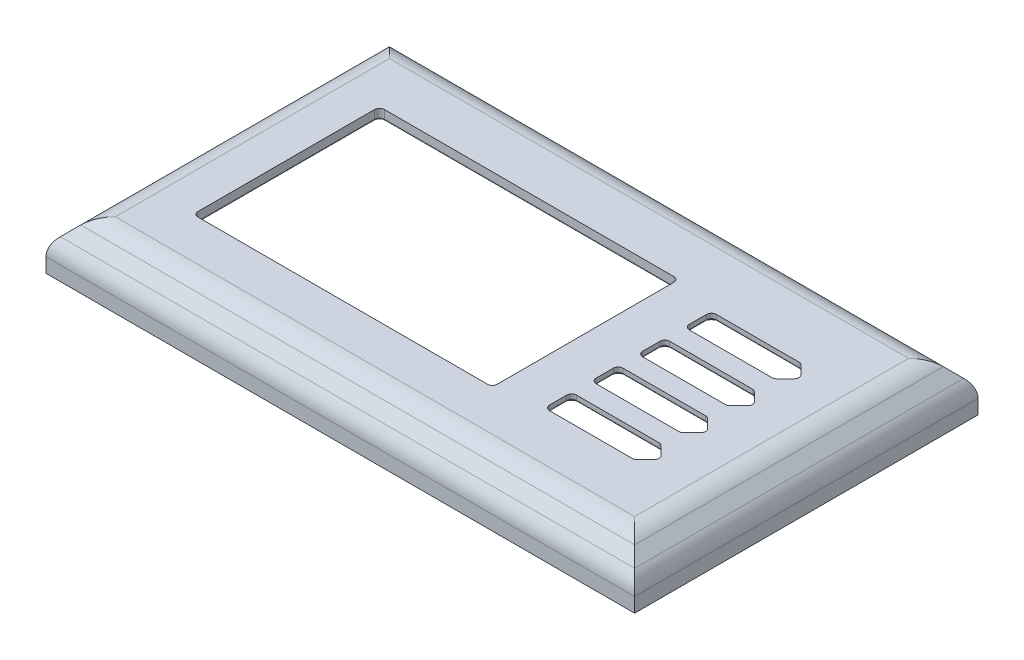
from build123d import *

# Parameters (mm, degrees)
SKETCH1_W           = 120
SKETCH1_H           = 70
BOSS_EXTRUDE1_DEPTH = 10
CHAMFER1_SIZE       = 5
SHELL1_T            = -2
SKETCH2_W           = 61
SKETCH2_H           = 38
CUT_EXTRUDE1_DEPTH  = 11
FILLET8_R           = 1
FILLET10_R          = 5
CUT_EXTRUDE3_DEPTH  = 0.8
FILLET12_R          = 0.3
FILLET13_R          = 0.3
SKETCH4_W           = 116.2
SKETCH4_H           = 66.2
CUT_EXTRUDE6_DEPTH  = 2


with BuildPart() as part:
    # Sketch1 → Boss-Extrude1 (new body)
    with BuildSketch(Plane(origin=(0, 0, 0), x_dir=(1, 0, 0), z_dir=(0, 1, 0))):
        with Locations((60, 35)):
            Rectangle(SKETCH1_W, SKETCH1_H)
    extrude(amount=BOSS_EXTRUDE1_DEPTH)

    # Chamfer1
    chamfer1_edges = [part.edges().sort_by_distance(p)[0] for p in [
        (120, 10, -35),
        (60, 10, -70),
        (0, 10, -35),
        (60, 10, 0),
    ]]
    chamfer(chamfer1_edges, length=CHAMFER1_SIZE)

    # Shell1
    shell1_openings = [part.faces().sort_by_distance(p)[0] for p in [
        (60, 0, -35),
    ]]
    offset(amount=SHELL1_T, openings=shell1_openings, kind=Kind.INTERSECTION)

    # Sketch2 → Cut-Extrude1 (cut, through all)
    with BuildSketch(Plane(origin=(0, 10, 0), x_dir=(1, 0, 0), z_dir=(0, 1, 0))):
        with Locations((45.067653297, 34.427439967)):
            Rectangle(SKETCH2_W, SKETCH2_H)
        Polygon((84.567653297, 41.583069286), (84.567653297, 36.083069286), (102.817653297, 36.083069286), (105.567653297, 38.833069286), (102.817653297, 41.583069286), align=None)
        Polygon((105.567653297, 48.333069286), (102.817653297, 51.083069286), (84.567653297, 51.083069286), (84.567653297, 45.583069286), (102.817653297, 45.583069286), align=None)
        Polygon((84.567653297, 32.083069286), (84.567653297, 26.583069286), (102.817653297, 26.583069286), (105.567653297, 29.333069286), (102.817653297, 32.083069286), align=None)
        Polygon((84.567653297, 22.583069286), (84.567653297, 17.083069286), (102.817653297, 17.083069286), (105.567653297, 19.833069286), (102.817653297, 22.583069286), align=None)
    extrude(amount=-CUT_EXTRUDE1_DEPTH, mode=Mode.SUBTRACT)

    # Fillet8
    fillet8_edges = [part.edges().sort_by_distance(p)[0] for p in [
        (84.567653297, 9, -26.583069286),
        (84.567653297, 9, -32.083069286),
        (102.817653297, 9, -32.083069286),
        (105.567653297, 9, -29.333069286),
        (102.817653297, 9, -26.583069286),
        (84.567653297, 9, -17.083069286),
        (84.567653297, 9, -22.583069286),
        (102.817653297, 9, -22.583069286),
        (105.567653297, 9, -19.833069286),
        (102.817653297, 9, -17.083069286),
        (14.567653297, 9, -15.427439967),
        (14.567653297, 9, -53.427439967),
        (75.567653297, 9, -53.427439967),
        (75.567653297, 9, -15.427439967),
        (84.567653297, 9, -45.583069286),
        (84.567653297, 9, -51.083069286),
        (102.817653297, 9, -51.083069286),
        (105.567653297, 9, -48.333069286),
        (102.817653297, 9, -45.583069286),
        (84.567653297, 9, -36.083069286),
        (84.567653297, 9, -41.583069286),
        (102.817653297, 9, -41.583069286),
        (105.567653297, 9, -38.833069286),
        (102.817653297, 9, -36.083069286),
    ]]
    fillet(fillet8_edges, radius=FILLET8_R)

    # Fillet10
    fillet10_edges = [part.edges().sort_by_distance(p)[0] for p in [
        (60, 10, -5),
        (5, 10, -35),
        (60, 10, -65),
        (115, 10, -35),
        (120, 5, -35),
        (60, 5, -70),
        (0, 5, -35),
        (60, 5, 0),
        (2, 4.171572875, -35),
        (60, 4.171572875, -2),
        (118, 4.171572875, -35),
        (60, 4.171572875, -68),
        (60, 8, -5.828427125),
        (114.171572875, 8, -35),
        (60, 8, -64.171572875),
        (5.828427125, 8, -35),
    ]]
    fillet(fillet10_edges, radius=FILLET10_R)

    # Sketch3 → Cut-Extrude3 (cut)
    with BuildSketch(Plane.XZ.offset(-8)):
        with BuildLine():
            Line((83.567653297, -31.083069286), (83.567653297, -27.583069286))
            ThreePointArc((83.567653297, -27.583069286), (84.153439735, -26.168855723), (85.567653297, -25.583069286))
            Line((85.567653297, -25.583069286), (102.403439735, -25.583069286))
            ThreePointArc((102.403439735, -25.583069286), (103.168806599, -25.735310221), (103.817653297, -26.168855723))
            Line((103.817653297, -26.168855723), (105.567653297, -27.918855723))
            ThreePointArc((105.567653297, -27.918855723), (106.153439735, -29.333069286), (105.567653297, -30.747282848))
            Line((105.567653297, -30.747282848), (103.817653297, -32.497282848))
            ThreePointArc((103.817653297, -32.497282848), (103.168806599, -32.930828351), (102.403439735, -33.083069286))
            Line((102.403439735, -33.083069286), (85.567653297, -33.083069286))
            ThreePointArc((85.567653297, -33.083069286), (84.153439735, -32.497282848), (83.567653297, -31.083069286))
        make_face()
        with BuildLine():
            Line((103.817653297, -16.668855723), (105.567653297, -18.418855723))
            ThreePointArc((105.567653297, -18.418855723), (106.153439735, -19.833069286), (105.567653297, -21.247282848))
            Line((105.567653297, -21.247282848), (103.817653297, -22.997282848))
            ThreePointArc((103.817653297, -22.997282848), (103.168806599, -23.430828351), (102.403439735, -23.583069286))
            Line((102.403439735, -23.583069286), (85.567653297, -23.583069286))
            ThreePointArc((85.567653297, -23.583069286), (84.153439735, -22.997282848), (83.567653297, -21.583069286))
            Line((83.567653297, -21.583069286), (83.567653297, -18.083069286))
            ThreePointArc((83.567653297, -18.083069286), (84.153439735, -16.668855723), (85.567653297, -16.083069286))
            Line((85.567653297, -16.083069286), (102.403439735, -16.083069286))
            ThreePointArc((102.403439735, -16.083069286), (103.168806599, -16.235310221), (103.817653297, -16.668855723))
        make_face()
        with BuildLine():
            Line((83.567653297, -40.583069286), (83.567653297, -37.083069286))
            ThreePointArc((83.567653297, -37.083069286), (84.153439735, -35.668855723), (85.567653297, -35.083069286))
            Line((85.567653297, -35.083069286), (102.403439735, -35.083069286))
            ThreePointArc((102.403439735, -35.083069286), (103.168806599, -35.235310221), (103.817653297, -35.668855723))
            Line((103.817653297, -35.668855723), (105.567653297, -37.418855723))
            ThreePointArc((105.567653297, -37.418855723), (106.153439735, -38.833069286), (105.567653297, -40.247282848))
            Line((105.567653297, -40.247282848), (103.817653297, -41.997282848))
            ThreePointArc((103.817653297, -41.997282848), (103.168806599, -42.430828351), (102.403439735, -42.583069286))
            Line((102.403439735, -42.583069286), (85.567653297, -42.583069286))
            ThreePointArc((85.567653297, -42.583069286), (84.153439735, -41.997282848), (83.567653297, -40.583069286))
        make_face()
        with BuildLine():
            Line((83.567653297, -50.083069286), (83.567653297, -46.583069286))
            ThreePointArc((83.567653297, -46.583069286), (84.153439735, -45.168855723), (85.567653297, -44.583069286))
            Line((85.567653297, -44.583069286), (102.403439735, -44.583069286))
            ThreePointArc((102.403439735, -44.583069286), (103.168806599, -44.735310221), (103.817653297, -45.168855723))
            Line((103.817653297, -45.168855723), (105.567653297, -46.918855723))
            ThreePointArc((105.567653297, -46.918855723), (106.153439735, -48.333069286), (105.567653297, -49.747282848))
            Line((105.567653297, -49.747282848), (103.817653297, -51.497282848))
            ThreePointArc((103.817653297, -51.497282848), (103.168806599, -51.930828351), (102.403439735, -52.083069286))
            Line((102.403439735, -52.083069286), (85.567653297, -52.083069286))
            ThreePointArc((85.567653297, -52.083069286), (84.153439735, -51.497282848), (83.567653297, -50.083069286))
        make_face()
    extrude(amount=-CUT_EXTRUDE3_DEPTH, mode=Mode.SUBTRACT)

    # Fillet12
    fillet12_edges = [part.edges().sort_by_distance(p)[0] for p in [
        (105.153439735, 8.8, -29.333069286),
        (93.985546516, 8.8, -32.083069286),
        (103.985546516, 8.8, -30.915176067),
        (103.985546516, 8.8, -27.750962504),
        (103.168806599, 8, -32.930828351),
        (104.692653297, 8, -31.622282848),
        (106.153439735, 8, -29.333069286),
        (104.692653297, 8, -27.043855723),
        (103.168806599, 8, -25.735310221),
        (93.985546516, 8, -25.583069286),
        (84.153439735, 8, -26.168855723),
        (83.567653297, 8, -29.333069286),
        (84.153439735, 8, -32.497282848),
        (93.985546516, 8, -33.083069286),
        (84.860546516, 8.8, -31.790176067),
        (84.567653297, 8.8, -29.333069286),
        (84.860546516, 8.8, -26.875962504),
        (93.985546516, 8.8, -26.583069286),
        (102.786123167, 8.8, -26.659189753),
        (102.786123167, 8.8, -32.006948818),
        (105.153439735, 8.8, -19.833069286),
        (93.985546516, 8.8, -22.583069286),
        (103.985546516, 8.8, -21.415176067),
        (103.985546516, 8.8, -18.250962504),
        (103.168806599, 8, -23.430828351),
        (104.692653297, 8, -22.122282848),
        (106.153439735, 8, -19.833069286),
        (104.692653297, 8, -17.543855723),
        (103.168806599, 8, -16.235310221),
        (93.985546516, 8, -16.083069286),
        (84.153439735, 8, -16.668855723),
        (83.567653297, 8, -19.833069286),
        (84.153439735, 8, -22.997282848),
        (93.985546516, 8, -23.583069286),
        (84.860546516, 8.8, -22.290176067),
        (84.567653297, 8.8, -19.833069286),
        (84.860546516, 8.8, -17.375962504),
        (93.985546516, 8.8, -17.083069286),
        (102.786123167, 8.8, -17.159189753),
        (102.786123167, 8.8, -22.506948818),
        (105.153439735, 8.8, -38.833069286),
        (93.985546516, 8.8, -41.583069286),
        (103.985546516, 8.8, -40.415176067),
        (103.985546516, 8.8, -37.250962504),
        (103.168806599, 8, -42.430828351),
        (104.692653297, 8, -41.122282848),
        (106.153439735, 8, -38.833069286),
        (104.692653297, 8, -36.543855723),
        (103.168806599, 8, -35.235310221),
        (93.985546516, 8, -35.083069286),
        (84.153439735, 8, -35.668855723),
        (83.567653297, 8, -38.833069286),
        (84.153439735, 8, -41.997282848),
        (93.985546516, 8, -42.583069286),
        (84.860546516, 8.8, -41.290176067),
        (84.567653297, 8.8, -38.833069286),
        (84.860546516, 8.8, -36.375962504),
        (93.985546516, 8.8, -36.083069286),
        (102.786123167, 8.8, -36.159189753),
        (102.786123167, 8.8, -41.506948818),
        (105.153439735, 8.8, -48.333069286),
        (93.985546516, 8.8, -51.083069286),
        (103.985546516, 8.8, -49.915176067),
        (103.985546516, 8.8, -46.750962504),
        (103.168806599, 8, -51.930828351),
        (104.692653297, 8, -50.622282848),
        (106.153439735, 8, -48.333069286),
        (104.692653297, 8, -46.043855723),
        (103.168806599, 8, -44.735310221),
        (93.985546516, 8, -44.583069286),
        (84.153439735, 8, -45.168855723),
        (83.567653297, 8, -48.333069286),
        (84.153439735, 8, -51.497282848),
        (93.985546516, 8, -52.083069286),
        (84.860546516, 8.8, -50.790176067),
        (84.567653297, 8.8, -48.333069286),
        (84.860546516, 8.8, -45.875962504),
        (93.985546516, 8.8, -45.583069286),
        (102.786123167, 8.8, -45.659189753),
        (102.786123167, 8.8, -51.006948818),
    ]]
    fillet(fillet12_edges, radius=FILLET12_R)

    # Fillet13
    fillet13_edges = [part.edges().sort_by_distance(p)[0] for p in [
        (75.567653297, 8, -34.427439967),
        (45.067653297, 8, -15.427439967),
        (45.067653297, 8, -53.427439967),
        (14.567653297, 8, -34.427439967),
        (75.274760078, 8, -15.720333186),
        (75.274760078, 8, -53.134546748),
        (14.860546516, 8, -53.134546748),
        (14.860546516, 8, -15.720333186),
    ]]
    fillet(fillet13_edges, radius=FILLET13_R)

    # Sketch4 → Cut-Extrude6 (cut)
    with BuildSketch(Plane.XZ):
        with Locations((60, -35)):
            Rectangle(SKETCH4_W, SKETCH4_H)
    extrude(amount=-CUT_EXTRUDE6_DEPTH, mode=Mode.SUBTRACT)


solid = part.part
